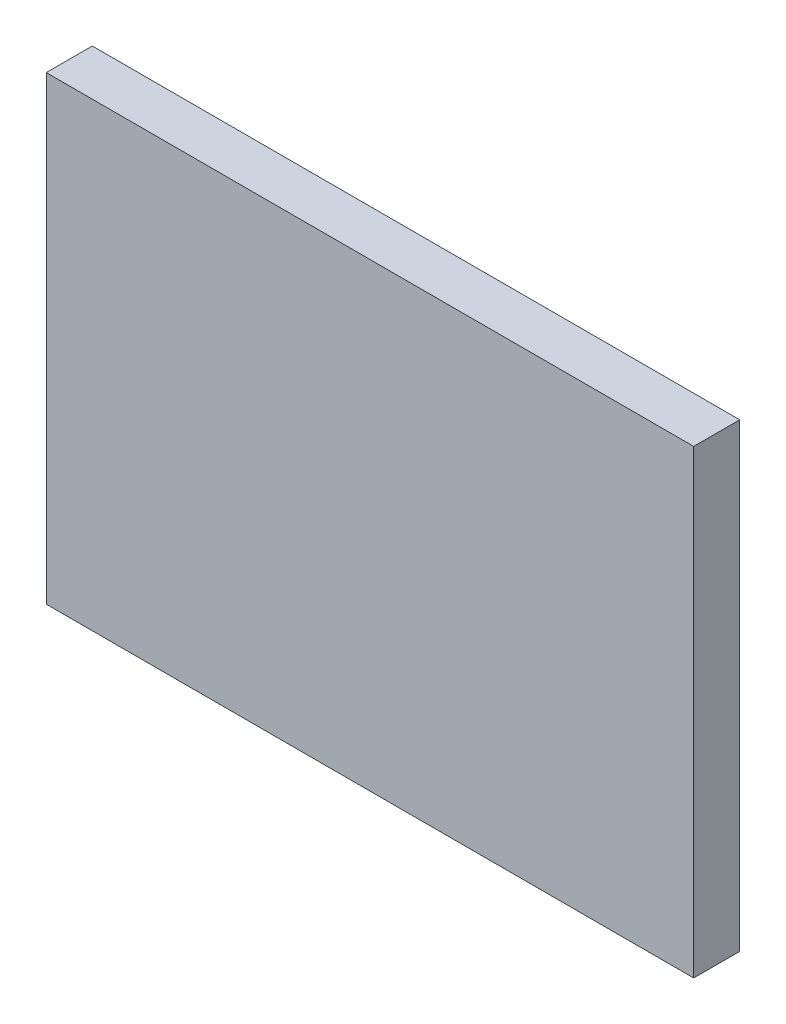
from build123d import *

# Parameters (mm, degrees)
SKETCH1_W           = 22.5
SKETCH1_H           = 16
BOSS_EXTRUDE1_DEPTH = 1.6


with BuildPart() as part:
    # Sketch1 → Boss-Extrude1 (new body)
    with BuildSketch(Plane.XY):
        Rectangle(SKETCH1_W, SKETCH1_H)
    extrude(amount=BOSS_EXTRUDE1_DEPTH)


solid = part.part
